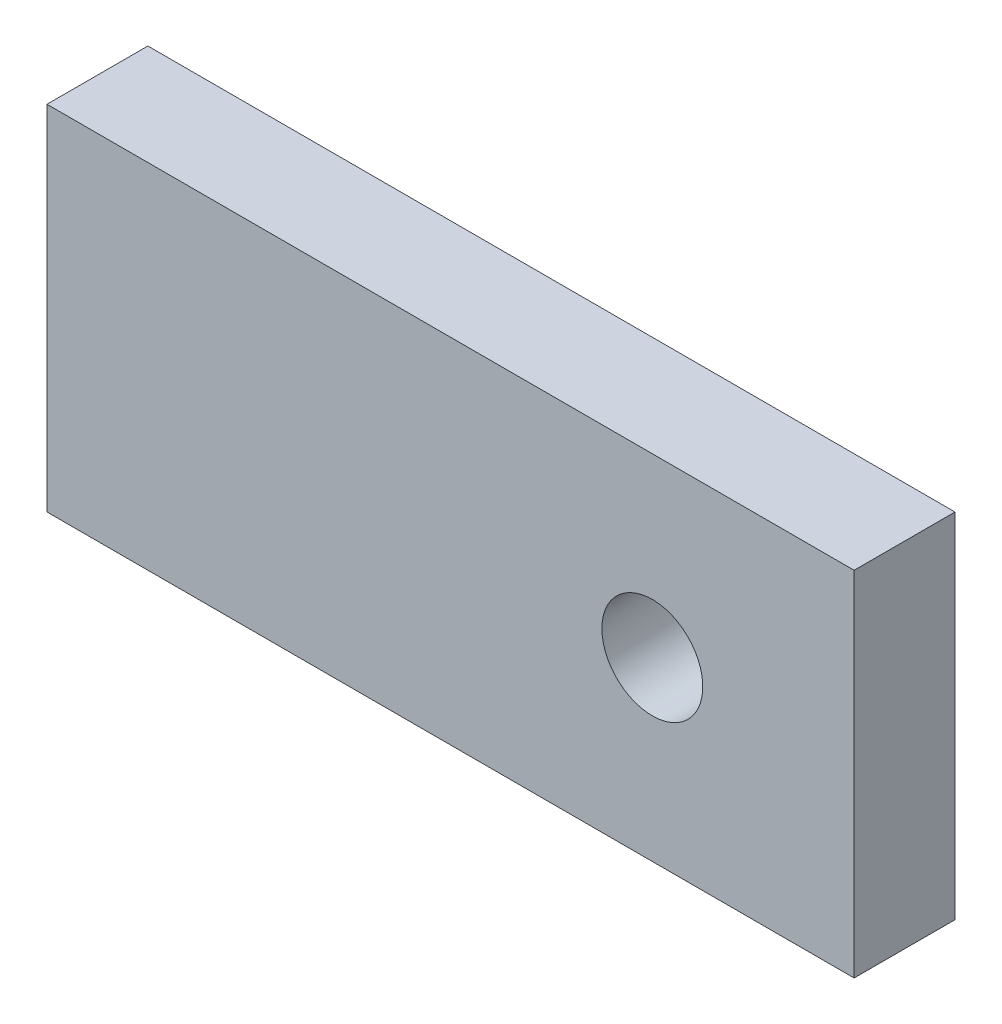
from build123d import *

# Parameters (mm, degrees)
SKETCH1_R                   = 2.540797377
SKETCH1_W                   = 50.8
SKETCH1_H                   = 22.225
BOSS_EXTRUDE1_DEPTH         = 6.35
F_1_4_0_25_DIAMETER_HOLE1_D = 6.35


with BuildPart() as part:
    # Sketch1 → Boss-Extrude1 (new body)
    with BuildSketch(Plane.XY):
        with Locations((12.7, 0)):
            Circle(SKETCH1_R)
        Rectangle(SKETCH1_W, SKETCH1_H)
        with Locations((12.7, 0)):
            Circle(SKETCH1_R, mode=Mode.SUBTRACT)
    extrude(amount=BOSS_EXTRUDE1_DEPTH)

    # 1/4 (0.25) Diameter Hole1 (through all)
    with Locations(Plane(origin=(0, 0, 0), x_dir=(-1, 0, 0), z_dir=(0, 0, -1))):
        with Locations((-12.7, 0)):
            Hole(F_1_4_0_25_DIAMETER_HOLE1_D / 2)


solid = part.part
